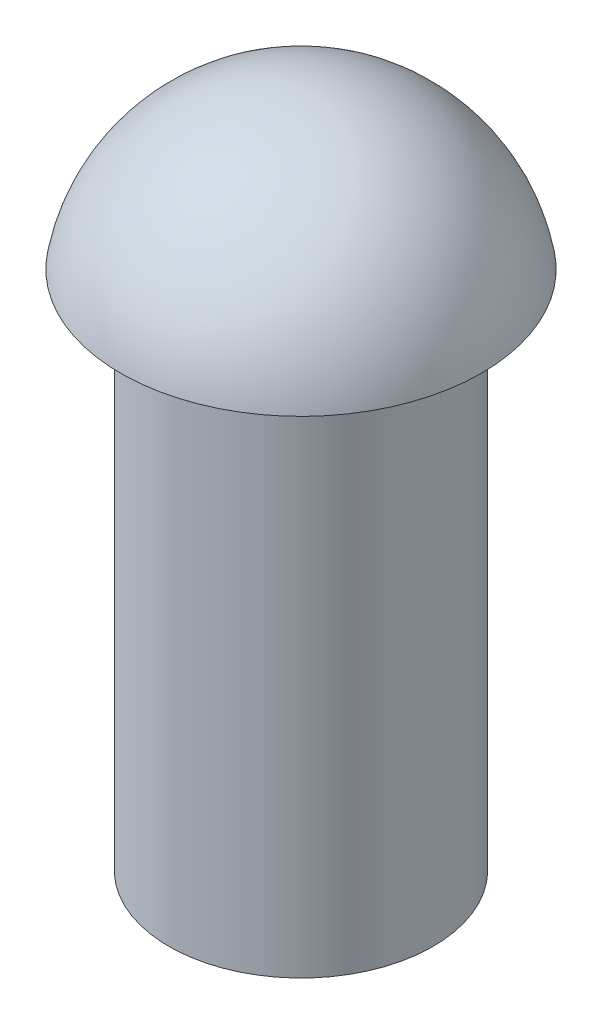
from build123d import *


with BuildPart() as part:
    # Sketch1 → Revolve1 (revolve)
    with BuildSketch(Plane.XY):
        with BuildLine():
            Line((0, 0), (3.231067894, 0))
            Line((3.231067894, 0), (3.231067894, 12.739639126))
            Line((3.231067894, 12.739639126), (4.415199877, 12.739639126))
            ThreePointArc((4.415199877, 12.739639126), (2.888302111, 15.408950176), (0, 16.464577565))
            Line((0, 16.464577565), (0, 0))
        make_face()
    revolve(axis=Axis((0, 0, 0), (0, 1, 0)))


solid = part.part
